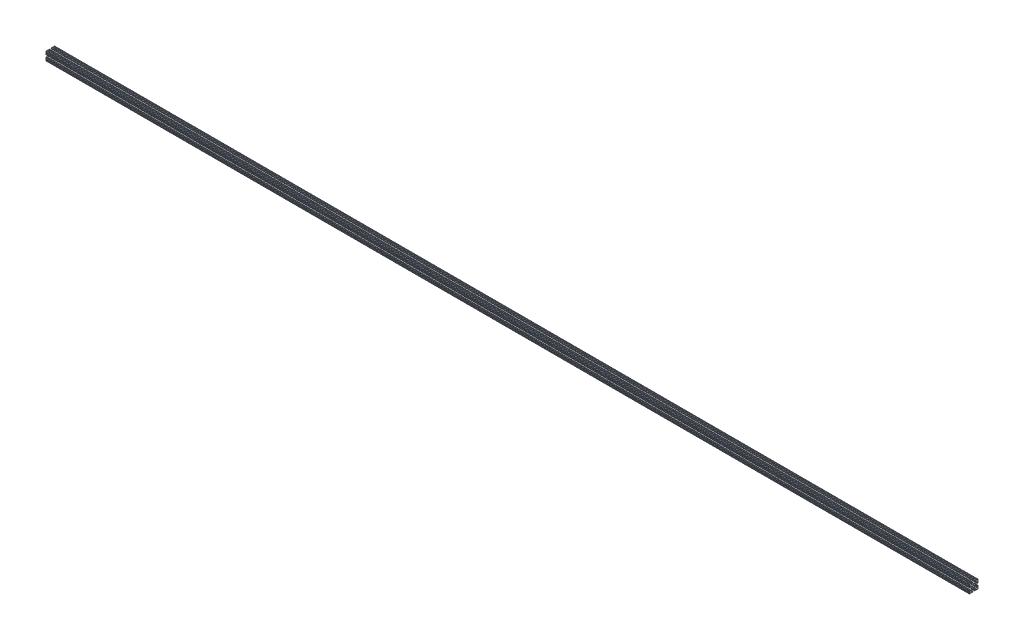
from build123d import *

# Parameters (mm, degrees)
BOSS_EXTRUDE1_DEPTH = 2692.4
SKETCH2_R           = 2.6035
CUT_EXTRUDE1_DEPTH  = 2692.4


with BuildPart() as part:
    # Sketch1 → Boss-Extrude1 (new body)
    with BuildSketch(Plane(origin=(0, 0, 0), x_dir=(0, 0, -1), z_dir=(1, 0, 0))):
        with BuildLine():
            Line((-2.6035, 11.938), (-2.6035, 10.922))
            ThreePointArc((-2.6035, 10.922), (-2.826684633, 10.383184633), (-3.3655, 10.16))
            Line((-3.3655, 10.16), (-5.780369265, 10.16))
            ThreePointArc((-5.780369265, 10.16), (-6.484365469, 9.689604775), (-6.319184633, 8.859184633))
            Line((-6.319184633, 8.859184633), (-2.826684633, 5.366684633))
            ThreePointArc((-2.826684633, 5.366684633), (-2.579474041, 5.201503796), (-2.287869265, 5.1435))
            Line((-2.287869265, 5.1435), (2.287869265, 5.1435))
            ThreePointArc((2.287869265, 5.1435), (2.579474041, 5.201503796), (2.826684633, 5.366684633))
            Line((2.826684633, 5.366684633), (6.319184633, 8.859184633))
            ThreePointArc((6.319184633, 8.859184633), (6.484365469, 9.689604775), (5.780369265, 10.16))
            Line((5.780369265, 10.16), (3.3655, 10.16))
            ThreePointArc((3.3655, 10.16), (2.826684633, 10.383184633), (2.6035, 10.922))
            Line((2.6035, 10.922), (2.6035, 11.938))
            ThreePointArc((2.6035, 11.938), (2.826684633, 12.476815367), (3.3655, 12.7))
            Line((3.3655, 12.7), (5.2917598, 12.7))
            ThreePointArc((5.2917598, 12.7), (5.9267598, 12.065), (6.5617598, 12.7))
            Line((6.5617598, 12.7), (8.6783418, 12.7))
            ThreePointArc((8.6783418, 12.7), (9.3133418, 12.065), (9.9483418, 12.7))
            Line((9.9483418, 12.7), (11.938, 12.7))
            ThreePointArc((11.938, 12.7), (12.476815367, 12.476815367), (12.7, 11.938))
            Line((12.7, 11.938), (12.7, 9.9483418))
            ThreePointArc((12.7, 9.9483418), (12.065, 9.3133418), (12.7, 8.6783418))
            Line((12.7, 8.6783418), (12.7, 6.5616836))
            ThreePointArc((12.7, 6.5616836), (12.065, 5.9266836), (12.7, 5.2916836))
            Line((12.7, 5.2916836), (12.7, 3.3655))
            ThreePointArc((12.7, 3.3655), (12.476815367, 2.826684633), (11.938, 2.6035))
            Line((11.938, 2.6035), (10.922, 2.6035))
            ThreePointArc((10.922, 2.6035), (10.383184633, 2.826684633), (10.16, 3.3655))
            Line((10.16, 3.3655), (10.16, 5.780369265))
            ThreePointArc((10.16, 5.780369265), (9.689604775, 6.484365469), (8.859184633, 6.319184633))
            Line((8.859184633, 6.319184633), (5.366684633, 2.826684633))
            ThreePointArc((5.366684633, 2.826684633), (5.201503796, 2.579474041), (5.1435, 2.287869265))
            Line((5.1435, 2.287869265), (5.1435, -2.287869265))
            ThreePointArc((5.1435, -2.287869265), (5.201503796, -2.579474041), (5.366684633, -2.826684633))
            Line((5.366684633, -2.826684633), (8.859184633, -6.319184633))
            ThreePointArc((8.859184633, -6.319184633), (9.689604775, -6.484365469), (10.16, -5.780369265))
            Line((10.16, -5.780369265), (10.16, -3.3655))
            ThreePointArc((10.16, -3.3655), (10.383184633, -2.826684633), (10.922, -2.6035))
            Line((10.922, -2.6035), (11.938, -2.6035))
            ThreePointArc((11.938, -2.6035), (12.476815367, -2.826684633), (12.7, -3.3655))
            Line((12.7, -3.3655), (12.7, -5.2917598))
            ThreePointArc((12.7, -5.2917598), (12.065, -5.9267598), (12.7, -6.5617598))
            Line((12.7, -6.5617598), (12.7, -8.6783418))
            ThreePointArc((12.7, -8.6783418), (12.065, -9.3133418), (12.7, -9.9483418))
            Line((12.7, -9.9483418), (12.7, -11.938))
            ThreePointArc((12.7, -11.938), (12.476815367, -12.476815367), (11.938, -12.7))
            Line((11.938, -12.7), (9.9483418, -12.7))
            ThreePointArc((9.9483418, -12.7), (9.3133418, -12.065), (8.6783418, -12.7))
            Line((8.6783418, -12.7), (6.5616836, -12.7))
            ThreePointArc((6.5616836, -12.7), (5.9266836, -12.065), (5.2916836, -12.7))
            Line((5.2916836, -12.7), (3.3655, -12.7))
            ThreePointArc((3.3655, -12.7), (2.826684633, -12.476815367), (2.6035, -11.938))
            Line((2.6035, -11.938), (2.6035, -10.922))
            ThreePointArc((2.6035, -10.922), (2.826684633, -10.383184633), (3.3655, -10.16))
            Line((3.3655, -10.16), (5.780369265, -10.16))
            ThreePointArc((5.780369265, -10.16), (6.484365469, -9.689604775), (6.319184633, -8.859184633))
            Line((6.319184633, -8.859184633), (2.826684633, -5.366684633))
            ThreePointArc((2.826684633, -5.366684633), (2.579474041, -5.201503796), (2.287869265, -5.1435))
            Line((2.287869265, -5.1435), (-2.287869265, -5.1435))
            ThreePointArc((-2.287869265, -5.1435), (-2.579474041, -5.201503796), (-2.826684633, -5.366684633))
            Line((-2.826684633, -5.366684633), (-6.319184633, -8.859184633))
            ThreePointArc((-6.319184633, -8.859184633), (-6.484365469, -9.689604775), (-5.780369265, -10.16))
            Line((-5.780369265, -10.16), (-3.3655, -10.16))
            ThreePointArc((-3.3655, -10.16), (-2.826684633, -10.383184633), (-2.6035, -10.922))
            Line((-2.6035, -10.922), (-2.6035, -11.938))
            ThreePointArc((-2.6035, -11.938), (-2.826684633, -12.476815367), (-3.3655, -12.7))
            Line((-3.3655, -12.7), (-5.2917598, -12.7))
            ThreePointArc((-5.2917598, -12.7), (-5.9267598, -12.065), (-6.5617598, -12.7))
            Line((-6.5617598, -12.7), (-8.6783418, -12.7))
            ThreePointArc((-8.6783418, -12.7), (-9.3133418, -12.065), (-9.9483418, -12.7))
            Line((-9.9483418, -12.7), (-11.938, -12.7))
            ThreePointArc((-11.938, -12.7), (-12.476815367, -12.476815367), (-12.7, -11.938))
            Line((-12.7, -11.938), (-12.7, -9.9483418))
            ThreePointArc((-12.7, -9.9483418), (-12.065, -9.3133418), (-12.7, -8.6783418))
            Line((-12.7, -8.6783418), (-12.7, -6.5616836))
            ThreePointArc((-12.7, -6.5616836), (-12.065, -5.9266836), (-12.7, -5.2916836))
            Line((-12.7, -5.2916836), (-12.7, -3.3655))
            ThreePointArc((-12.7, -3.3655), (-12.476815367, -2.826684633), (-11.938, -2.6035))
            Line((-11.938, -2.6035), (-10.922, -2.6035))
            ThreePointArc((-10.922, -2.6035), (-10.383184633, -2.826684633), (-10.16, -3.3655))
            Line((-10.16, -3.3655), (-10.16, -5.780369265))
            ThreePointArc((-10.16, -5.780369265), (-9.689604775, -6.484365469), (-8.859184633, -6.319184633))
            Line((-8.859184633, -6.319184633), (-5.366684633, -2.826684633))
            ThreePointArc((-5.366684633, -2.826684633), (-5.201503796, -2.579474041), (-5.1435, -2.287869265))
            Line((-5.1435, -2.287869265), (-5.1435, 2.287869265))
            ThreePointArc((-5.1435, 2.287869265), (-5.201503796, 2.579474041), (-5.366684633, 2.826684633))
            Line((-5.366684633, 2.826684633), (-8.859184633, 6.319184633))
            ThreePointArc((-8.859184633, 6.319184633), (-9.689604775, 6.484365469), (-10.16, 5.780369265))
            Line((-10.16, 5.780369265), (-10.16, 3.3655))
            ThreePointArc((-10.16, 3.3655), (-10.383184633, 2.826684633), (-10.922, 2.6035))
            Line((-10.922, 2.6035), (-11.938, 2.6035))
            ThreePointArc((-11.938, 2.6035), (-12.476815367, 2.826684633), (-12.7, 3.3655))
            Line((-12.7, 3.3655), (-12.7, 5.2917598))
            ThreePointArc((-12.7, 5.2917598), (-12.065, 5.9267598), (-12.7, 6.5617598))
            Line((-12.7, 6.5617598), (-12.7, 8.6783418))
            ThreePointArc((-12.7, 8.6783418), (-12.065, 9.3133418), (-12.7, 9.9483418))
            Line((-12.7, 9.9483418), (-12.7, 11.938))
            ThreePointArc((-12.7, 11.938), (-12.476815367, 12.476815367), (-11.938, 12.7))
            Line((-11.938, 12.7), (-9.9483418, 12.7))
            ThreePointArc((-9.9483418, 12.7), (-9.3133418, 12.065), (-8.6783418, 12.7))
            Line((-8.6783418, 12.7), (-6.5616836, 12.7))
            ThreePointArc((-6.5616836, 12.7), (-5.9266836, 12.065), (-5.2916836, 12.7))
            Line((-5.2916836, 12.7), (-3.3655, 12.7))
            ThreePointArc((-3.3655, 12.7), (-2.826684633, 12.476815367), (-2.6035, 11.938))
        make_face()
    extrude(amount=BOSS_EXTRUDE1_DEPTH)

    # Sketch2 → Cut-Extrude1 (cut)
    with BuildSketch(Plane.ZY):
        Circle(SKETCH2_R)
    extrude(amount=-CUT_EXTRUDE1_DEPTH, mode=Mode.SUBTRACT)


solid = part.part
